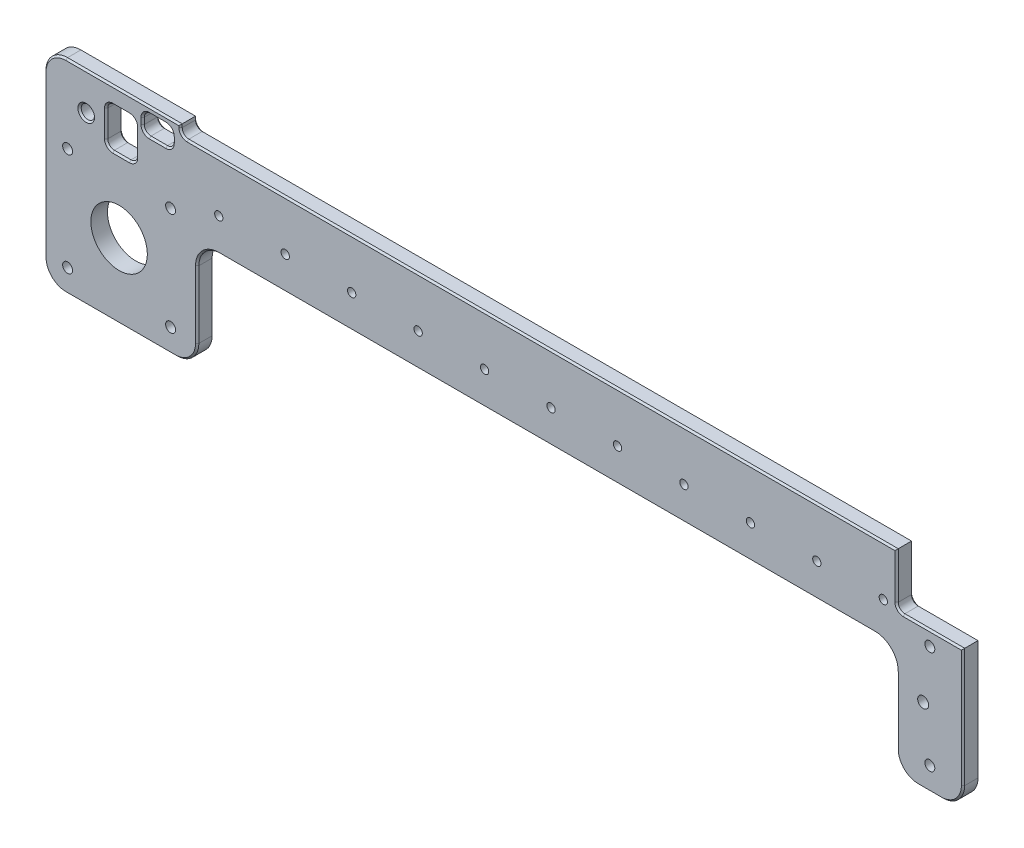
from build123d import *

# Parameters (mm, degrees)
SKETCH1_R           = 1.25
SKETCH1_R_2         = 8.5
SKETCH1_R_3         = 1.5
SKETCH1_R_4         = 1.65
SKETCH1_R_5         = 2
BOSS_EXTRUDE1_DEPTH = 5
CHAMFER1_SIZE       = 0.5


with BuildPart() as part:
    # Sketch1 → Boss-Extrude1 (new body)
    with BuildSketch(Plane.XY):
        with BuildLine():
            Line((0, -10), (197.5, -10))
            ThreePointArc((197.5, -10), (202.096194078, -11.903805922), (204, -16.5))
            Line((204, -16.5), (204, -36.746197724))
            ThreePointArc((204, -36.746197724), (205.903805922, -41.342391801), (210.5, -43.246197724))
            Line((210.5, -43.246197724), (217.5, -43.246197724))
            ThreePointArc((217.5, -43.246197724), (222.096194078, -41.342391801), (224, -36.746197724))
            Line((224, -36.746197724), (224, -0.946197724))
            Line((224, -0.946197724), (206, -0.946197724))
            ThreePointArc((206, -0.946197724), (204.585786438, -0.360411286), (204, 1.053802276))
            Line((204, 1.053802276), (204, 15))
            Line((204, 15), (-9.5, 15))
            ThreePointArc((-9.5, 15), (-10.914213562, 15.585786438), (-11.5, 17))
            Line((-11.5, 17), (-11.5, 18))
            Line((-11.5, 18), (-46, 18))
            ThreePointArc((-46, 18), (-50.596194078, 16.096194078), (-52.5, 11.5))
            Line((-52.5, 11.5), (-52.5, -36.746197724))
            ThreePointArc((-52.5, -36.746197724), (-50.596194078, -41.342391801), (-46, -43.246197724))
            Line((-46, -43.246197724), (-13, -43.246197724))
            ThreePointArc((-13, -43.246197724), (-8.403805922, -41.342391801), (-6.5, -36.746197724))
            Line((-6.5, -36.746197724), (-6.5, -16.5))
            ThreePointArc((-6.5, -16.5), (-4.596194078, -11.903805922), (0, -10))
        make_face()
        Circle(SKETCH1_R, mode=Mode.SUBTRACT)
        with Locations((20, 0)):
            Circle(SKETCH1_R, mode=Mode.SUBTRACT)
        with Locations((40, 0)):
            Circle(SKETCH1_R, mode=Mode.SUBTRACT)
        with Locations((60, 0)):
            Circle(SKETCH1_R, mode=Mode.SUBTRACT)
        with Locations((80, 0)):
            Circle(SKETCH1_R, mode=Mode.SUBTRACT)
        with Locations((100, 0)):
            Circle(SKETCH1_R, mode=Mode.SUBTRACT)
        with Locations((120, 0)):
            Circle(SKETCH1_R, mode=Mode.SUBTRACT)
        with Locations((140, 0)):
            Circle(SKETCH1_R, mode=Mode.SUBTRACT)
        with Locations((160, 0)):
            Circle(SKETCH1_R, mode=Mode.SUBTRACT)
        with Locations((180, 0)):
            Circle(SKETCH1_R, mode=Mode.SUBTRACT)
        with Locations((-30, -20.746197724)):
            Circle(SKETCH1_R_2, mode=Mode.SUBTRACT)
        with Locations((-45.5, -5.246197724)):
            Circle(SKETCH1_R_3, mode=Mode.SUBTRACT)
        with Locations((-14.5, -5.246197724)):
            Circle(SKETCH1_R_3, mode=Mode.SUBTRACT)
        with Locations((-45.5, -36.246197724)):
            Circle(SKETCH1_R_3, mode=Mode.SUBTRACT)
        with Locations((-14.5, -36.246197724)):
            Circle(SKETCH1_R_3, mode=Mode.SUBTRACT)
        with Locations((200, 0)):
            Circle(SKETCH1_R, mode=Mode.SUBTRACT)
        with Locations((212, -20.746197724)):
            Circle(SKETCH1_R_4, mode=Mode.SUBTRACT)
        with Locations((214, -36.246197724)):
            Circle(SKETCH1_R_3, mode=Mode.SUBTRACT)
        with Locations((214, -5.246197724)):
            Circle(SKETCH1_R_3, mode=Mode.SUBTRACT)
        with Locations((-39.9, 6.9)):
            Circle(SKETCH1_R_5, mode=Mode.SUBTRACT)
        with BuildLine():
            Line((-20.9, 16), (-15.9, 16))
            ThreePointArc((-15.9, 16), (-14.485786438, 15.414213562), (-13.9, 14))
            Line((-13.9, 14), (-13.9, 12.12))
            ThreePointArc((-13.9, 12.12), (-14.485786438, 10.705786438), (-15.9, 10.12))
            Line((-15.9, 10.12), (-20.9, 10.12))
            ThreePointArc((-20.9, 10.12), (-22.314213562, 10.705786438), (-22.9, 12.12))
            Line((-22.9, 12.12), (-22.9, 14))
            ThreePointArc((-22.9, 14), (-22.314213562, 15.414213562), (-20.9, 16))
        make_face(mode=Mode.SUBTRACT)
        with BuildLine():
            Line((-26.9, 12.9), (-31.9, 12.9))
            ThreePointArc((-31.9, 12.9), (-33.314213562, 12.314213562), (-33.9, 10.9))
            Line((-33.9, 10.9), (-33.9, 2.9))
            ThreePointArc((-33.9, 2.9), (-33.314213562, 1.485786438), (-31.9, 0.9))
            Line((-31.9, 0.9), (-26.9, 0.9))
            ThreePointArc((-26.9, 0.9), (-25.485786438, 1.485786438), (-24.9, 2.9))
            Line((-24.9, 2.9), (-24.9, 10.9))
            ThreePointArc((-24.9, 10.9), (-25.485786438, 12.314213562), (-26.9, 12.9))
        make_face(mode=Mode.SUBTRACT)
    extrude(amount=BOSS_EXTRUDE1_DEPTH)

    # Chamfer1
    chamfer1_edges = [part.edges().sort_by_distance(p)[0] for p in [
        (-14.485786438, 15.414213562, 0),
        (-18.4, 16, 0),
        (-22.314213562, 15.414213562, 0),
        (-22.9, 13.06, 0),
        (-22.314213562, 10.705786438, 0),
        (-18.4, 10.12, 0),
        (-14.485786438, 10.705786438, 0),
        (-13.9, 13.06, 0),
        (-14.485786438, 15.414213562, 5),
        (-18.4, 16, 5),
        (-22.314213562, 15.414213562, 5),
        (-22.9, 13.06, 5),
        (-22.314213562, 10.705786438, 5),
        (-18.4, 10.12, 5),
        (-14.485786438, 10.705786438, 5),
        (-13.9, 13.06, 5),
        (205.903805922, -41.342391801, 5),
        (-25.485786438, 12.314213562, 0),
        (-29.4, 12.9, 0),
        (-33.314213562, 12.314213562, 0),
        (-33.9, 6.9, 0),
        (-33.314213562, 1.485786438, 0),
        (-29.4, 0.9, 0),
        (-25.485786438, 1.485786438, 0),
        (-24.9, 6.9, 0),
        (-25.485786438, 12.314213562, 5),
        (-29.4, 12.9, 5),
        (-33.314213562, 12.314213562, 5),
        (-33.9, 6.9, 5),
        (-33.314213562, 1.485786438, 5),
        (-29.4, 0.9, 5),
        (-25.485786438, 1.485786438, 5),
        (-24.9, 6.9, 5),
        (214, -43.246197724, 5),
        (-41.9, 6.9, 0),
        (-41.9, 6.9, 5),
        (98.75, -10, 0),
        (-4.596194078, -11.903805922, 0),
        (222.096194078, -41.342391801, 5),
        (-6.5, -26.623098862, 0),
        (-8.403805922, -41.342391801, 0),
        (-29.5, -43.246197724, 0),
        (-50.596194078, -41.342391801, 0),
        (-52.5, -12.623098862, 0),
        (-50.596194078, 16.096194078, 0),
        (-28.75, 18, 0),
        (-11.5, 17.5, 0),
        (-10.914213562, 15.585786438, 0),
        (97.25, 15, 0),
        (224, -18.846197724, 5),
        (204, 8.026901138, 0),
        (204.585786438, -0.360411286, 0),
        (215, -0.946197724, 0),
        (224, -18.846197724, 0),
        (222.096194078, -41.342391801, 0),
        (214, -43.246197724, 0),
        (205.903805922, -41.342391801, 0),
        (204, -26.623098862, 0),
        (202.096194078, -11.903805922, 0),
        (215, -0.946197724, 5),
        (204.585786438, -0.360411286, 5),
        (204, 8.026901138, 5),
        (97.25, 15, 5),
        (-10.914213562, 15.585786438, 5),
        (-11.5, 17.5, 5),
        (202.096194078, -11.903805922, 5),
        (-28.75, 18, 5),
        (-50.596194078, 16.096194078, 5),
        (-52.5, -12.623098862, 5),
        (-50.596194078, -41.342391801, 5),
        (-29.5, -43.246197724, 5),
        (-8.403805922, -41.342391801, 5),
        (-6.5, -26.623098862, 5),
        (-4.596194078, -11.903805922, 5),
        (98.75, -10, 5),
        (204, -26.623098862, 5),
    ]]
    chamfer(chamfer1_edges, length=CHAMFER1_SIZE)


solid = part.part
